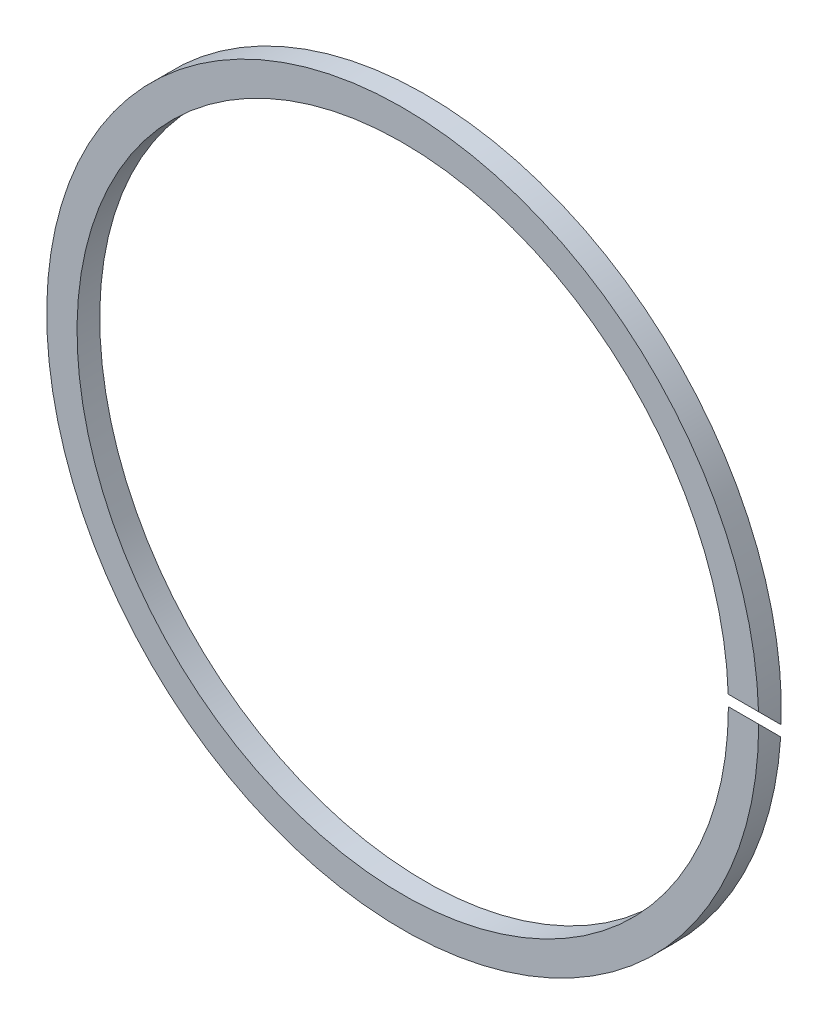
from build123d import *

# Parameters (mm, degrees)
SKETCH1_R           = 47
SKETCH1_R_2         = 43
BOSS_EXTRUDE1_DEPTH = 3
CUT_EXTRUDE1_DEPTH  = 67.535704701


with BuildPart() as part:
    # Sketch1 → Boss-Extrude1 (new body)
    with BuildSketch(Plane.XY):
        Circle(SKETCH1_R)
        Circle(SKETCH1_R_2, mode=Mode.SUBTRACT)
    extrude(amount=BOSS_EXTRUDE1_DEPTH)

    # Sketch3 → Cut-Extrude1 (cut, through all)
    with BuildSketch(Plane(origin=(0, 0, 0), x_dir=(0, 0, -1), z_dir=(1, 0, 0))):
        Polygon((-3, 0), (0, -3), (0.707106781, -2.292893219), (-3, 1.414213562), align=None)
    extrude(amount=CUT_EXTRUDE1_DEPTH, mode=Mode.SUBTRACT)


solid = part.part
